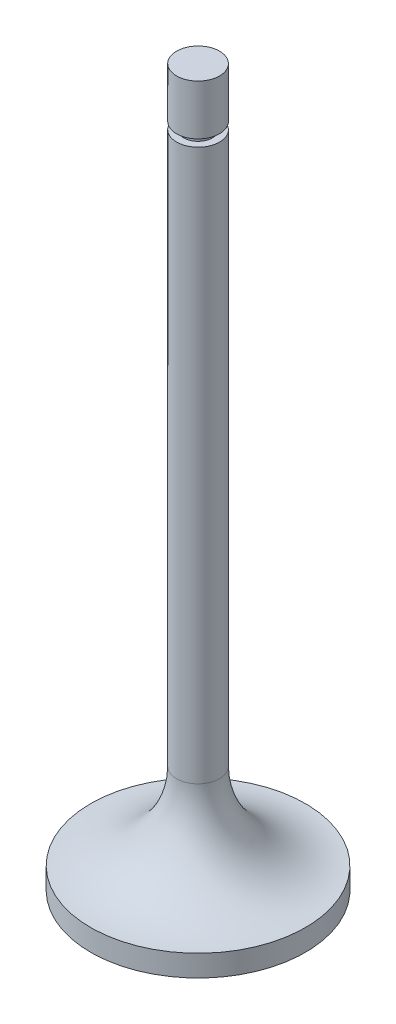
from build123d import *


with BuildPart() as part:
    # Sketch3 → Revolve1 (revolve)
    with BuildSketch(Plane.XY):
        with BuildLine():
            Line((0, 22.895408163), (0, 0))
            Line((0, 0), (0, -77.104591837))
            Line((0, -77.104591837), (15, -77.104591837))
            Line((15, -77.104591837), (15, -74.104591837))
            ThreePointArc((15, -74.104591837), (6.514718626, -70.589873211), (3, -62.104591837))
            Line((3, -62.104591837), (3, 14.895408163))
            Line((3, 14.895408163), (2, 14.895408163))
            Line((2, 14.895408163), (2, 15.895408163))
            Line((2, 15.895408163), (3, 15.895408163))
            Line((3, 15.895408163), (3, 22.895408163))
            Line((3, 22.895408163), (0, 22.895408163))
        make_face()
    revolve(axis=Axis((0, 103.649150199, 0), (0, -1, 0)))


solid = part.part
